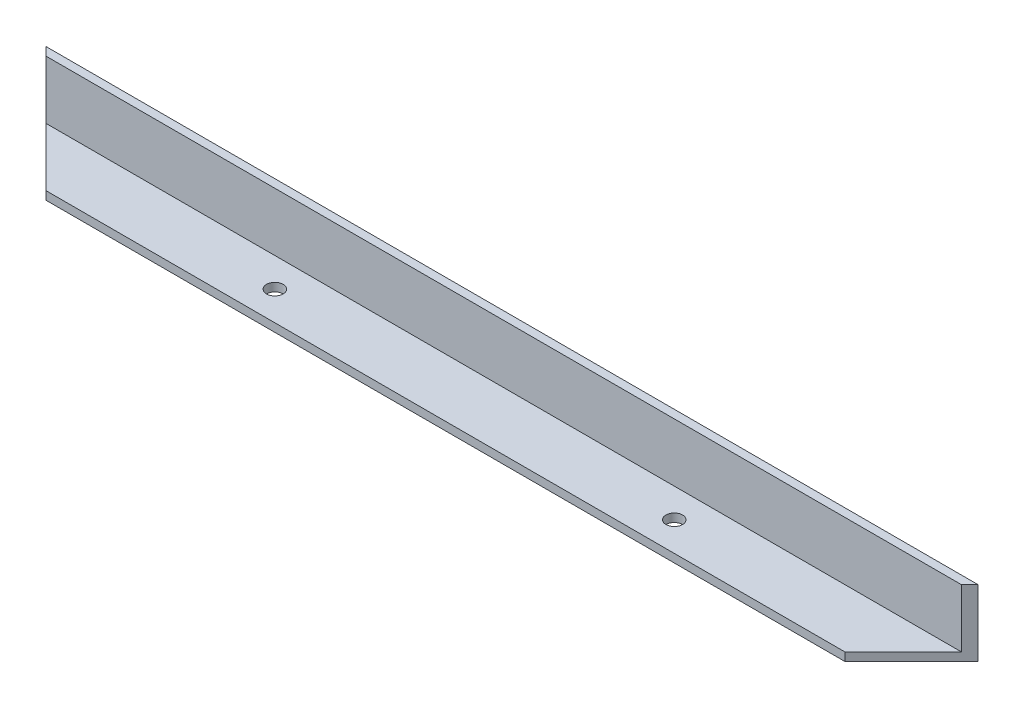
from build123d import *

# Parameters (mm, degrees)
SKETCH2_W           = 355.6
SKETCH2_H           = 25.4
BOSS_EXTRUDE1_DEPTH = 3.175
SKETCH3_W           = 355.6
SKETCH3_H           = 3.175
BOSS_EXTRUDE2_DEPTH = 22.225
CUT_EXTRUDE3_DEPTH  = 25.4
SKETCH7_R           = 3.175
CUT_EXTRUDE4_DEPTH  = 3.175


with BuildPart() as part:
    # Sketch2 → Boss-Extrude1 (new body)
    with BuildSketch(Plane(origin=(0, 0, 0), x_dir=(1, 0, 0), z_dir=(0, 1, 0))):
        with Locations((-177.8, -12.7)):
            Rectangle(SKETCH2_W, SKETCH2_H)
    extrude(amount=BOSS_EXTRUDE1_DEPTH)

    # Sketch3 → Boss-Extrude2 (add)
    with BuildSketch(Plane(origin=(0, 3.175, 0), x_dir=(1, 0, 0), z_dir=(0, 1, 0))):
        with Locations((-177.8, -1.5875)):
            Rectangle(SKETCH3_W, SKETCH3_H)
    extrude(amount=BOSS_EXTRUDE2_DEPTH)

    # Sketch6 → Cut-Extrude3 (cut)
    with BuildSketch(Plane(origin=(0, 25.4, 0), x_dir=(1, 0, 0), z_dir=(0, 1, 0))):
        Polygon((-355.6, 0), (-314.465679006, -41.134320994), (-387.836085875, -49.332490233), align=None)
        Polygon((0, 0), (-41.658764664, -41.658764664), (40.75579897, -53.520309566), align=None)
    extrude(amount=-CUT_EXTRUDE3_DEPTH, mode=Mode.SUBTRACT)

    # Sketch7 → Cut-Extrude4 (cut)
    with BuildSketch(Plane(origin=(0, 3.175, 0), x_dir=(1, 0, 0), z_dir=(0, 1, 0))):
        with Locations((-101.6, -14.2875)):
            Circle(SKETCH7_R)
        with Locations((-254, -14.2875)):
            Circle(SKETCH7_R)
    extrude(amount=-CUT_EXTRUDE4_DEPTH, mode=Mode.SUBTRACT)


solid = part.part
